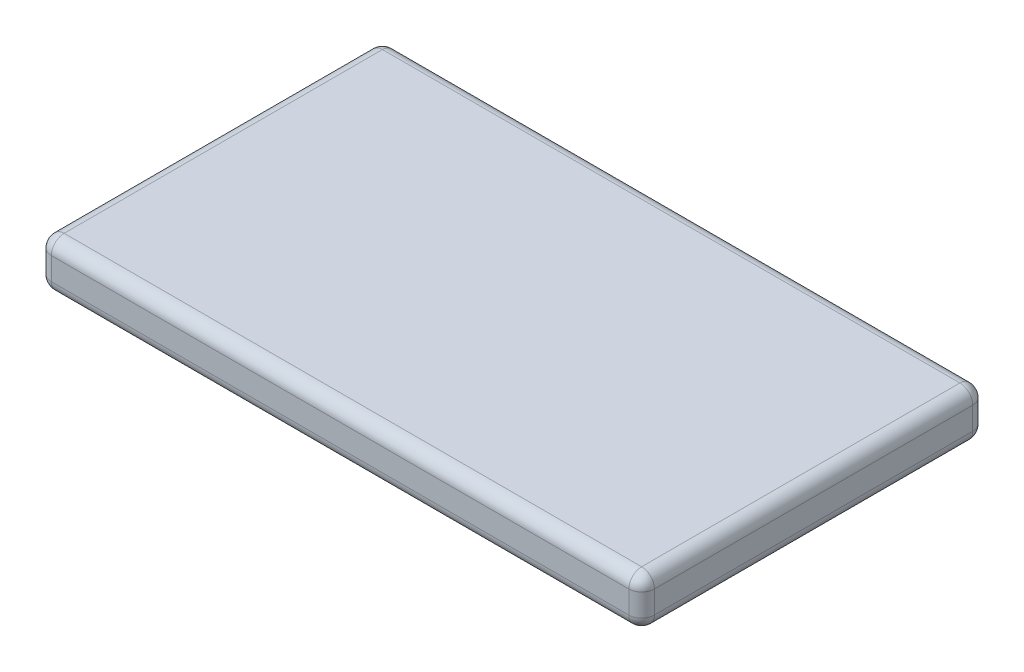
from build123d import *

# Parameters (mm, degrees)
SKETCH1_W           = 59.69
SKETCH1_H           = 34.036
BOSS_EXTRUDE1_DEPTH = 4.7752
FILLET1_R           = 1.27


with BuildPart() as part:
    # Sketch1 → Boss-Extrude1 (new body)
    with BuildSketch(Plane(origin=(0, 0, 0), x_dir=(1, 0, 0), z_dir=(0, 1, 0))):
        with Locations((29.845, 17.018)):
            Rectangle(SKETCH1_W, SKETCH1_H)
    extrude(amount=BOSS_EXTRUDE1_DEPTH)

    # Fillet1
    fillet1_edges = [part.edges().sort_by_distance(p)[0] for p in [
        (59.69, 4.7752, -17.018),
        (29.845, 4.7752, -34.036),
        (0, 4.7752, -17.018),
        (29.845, 0, -34.036),
        (59.69, 0, -17.018),
        (29.845, 0, 0),
        (0, 0, -17.018),
        (29.845, 4.7752, 0),
        (0, 2.3876, -34.036),
        (59.69, 2.3876, -34.036),
        (59.69, 2.3876, 0),
        (0, 2.3876, 0),
    ]]
    fillet(fillet1_edges, radius=FILLET1_R)


solid = part.part
